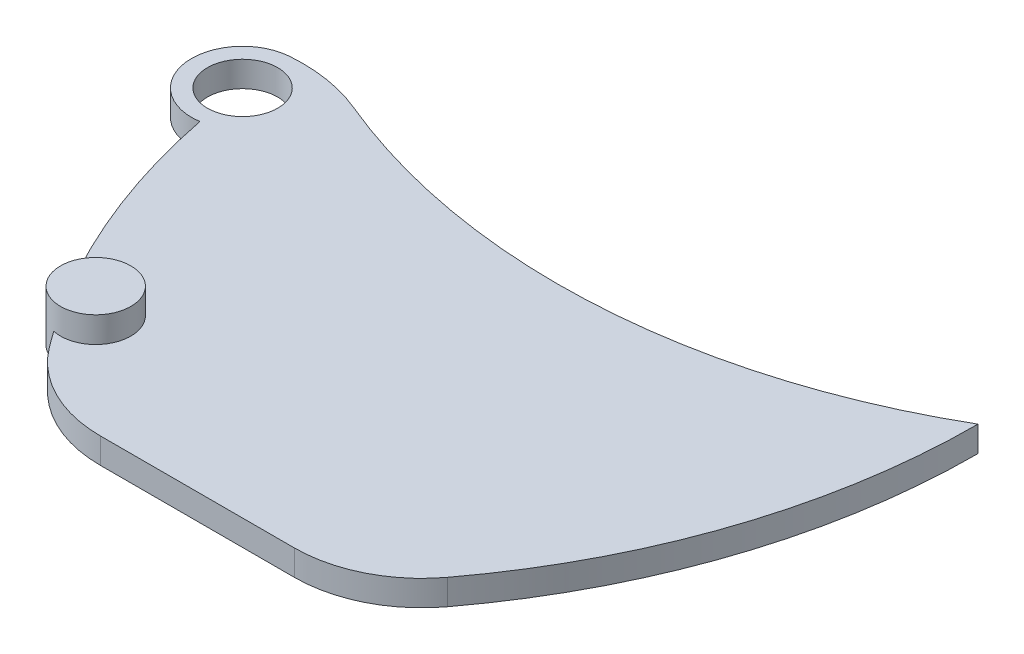
from build123d import *

# Parameters (mm, degrees)
BOSS_EXTRUDE1_DEPTH = 5
SKETCH2_R           = 4.5
CUT_EXTRUDE1_DEPTH  = 180.046458535
CUT_EXTRUDE2_START  = -25
CUT_EXTRUDE2_DEPTH  = 25
CUT_EXTRUDE3_START  = -25
CUT_EXTRUDE3_DEPTH  = 25
FILLET1_R           = 25
SCALE1_SCALE        = 0.225
CUT_EXTRUDE4_REACH  = 100.567
SKETCH5_R           = 1.55
SKETCH7_R           = 1.55
BOSS_EXTRUDE3_DEPTH = 2.26


with BuildPart() as part:
    # Sketch1 → Boss-Extrude1 (new body)
    with BuildSketch(Plane(origin=(0, 0, 0), x_dir=(1, 0, 0), z_dir=(0, 1, 0))):
        with BuildLine():
            ThreePointArc((-130, 0), (-129.975663124, -2.515351975), (-129.902661607, -5.029762169))
            ThreePointArc((-129.902661607, -5.029762169), (-139.064924602, -16.153846154), (-127.596676804, -24.881480435))
            ThreePointArc((-127.596676804, -24.881480435), (-105.812439614, -75.523027104), (-65, -112.583302492))
            ThreePointArc((-65, -112.583302492), (-17.416697508, -65), (0, 0))
            ThreePointArc((0, 0), (-65, -17.416697508), (-130, 0))
        make_face()
    extrude(amount=BOSS_EXTRUDE1_DEPTH)

    # Sketch2 → Cut-Extrude1 (cut, through all)
    with BuildSketch(Plane(origin=(0, 5, 0), x_dir=(1, 0, 0), z_dir=(0, 1, 0))):
        with Locations((-129.131715701, -15)):
            Circle(SKETCH2_R)
        with Locations((-104.833820993, -68.079879377)):
            Circle(SKETCH2_R)
    extrude(amount=-CUT_EXTRUDE1_DEPTH, mode=Mode.SUBTRACT)

    # Sketch3 → Cut-Extrude2 (cut)
    with BuildSketch(Plane(origin=(0, 5, 0), x_dir=(1, 0, 0), z_dir=(0, 1, 0)).offset(CUT_EXTRUDE2_START)):
        with BuildLine():
            Line((-34.313010289, -88), (-95.686989711, -88))
            ThreePointArc((-95.686989711, -88), (-81.278298801, -101.458553824), (-65, -112.583302492))
            ThreePointArc((-65, -112.583302492), (-48.721701199, -101.458553824), (-34.313010289, -88))
        make_face()
    extrude(amount=CUT_EXTRUDE2_DEPTH, mode=Mode.SUBTRACT)

    # Sketch4 → Cut-Extrude3 (cut)
    with BuildSketch(Plane(origin=(0, 5, 0), x_dir=(1, 0, 0), z_dir=(0, 1, 0)).offset(CUT_EXTRUDE3_START)):
        with BuildLine():
            ThreePointArc((-130, 0), (-129.975663124, -2.515351975), (-129.902661607, -5.029762169))
            ThreePointArc((-129.902661607, -5.029762169), (-122.310091762, -5.339865772), (-115.00045201, -7.416509169))
            ThreePointArc((-115.00045201, -7.416509169), (-122.619676697, -3.949838105), (-130, 0))
        make_face()
    extrude(amount=CUT_EXTRUDE3_DEPTH, mode=Mode.SUBTRACT)

    # Fillet1
    fillet1_edges = [part.edges().sort_by_distance(p)[0] for p in [
        (-34.313010289, 2.5, 88),
        (-95.686989711, 2.5, 88),
    ]]
    fillet(fillet1_edges, radius=FILLET1_R)


with BuildPart() as part_1:
    # Scale1: scaled about (-65.342168123, 2.5, 45.115535207)
    add(part.part.scale(SCALE1_SCALE).moved(Location((-50.640180295, 1.9375, 34.964539785))))

    # Sketch5 → Cut-Extrude4 (cut, up to next)
    with BuildSketch(Plane(origin=(0, 3.0625, 0), x_dir=(1, 0, 0), z_dir=(0, 1, 0)), mode=Mode.PRIVATE) as cut_extrude4_sk1:
        with Locations((-79.694816328, -38.339539786)):
            Circle(SKETCH5_R)
    cut_extrude4_tool1 = extrude(cut_extrude4_sk1.sketch, amount=-CUT_EXTRUDE4_REACH, mode=Mode.PRIVATE) & part_1.part
    add(cut_extrude4_tool1.solids().sort_by_distance((-79.694816, 3.0625, 38.33954))[0], mode=Mode.SUBTRACT)

    # Sketch7 → Boss-Extrude3 (add)
    with BuildSketch(Plane.XZ.offset(-1.9375)):
        with Locations((-74.227790019, 50.282512645)):
            Circle(SKETCH7_R)
    extrude(amount=-BOSS_EXTRUDE3_DEPTH)


solid = part_1.part
